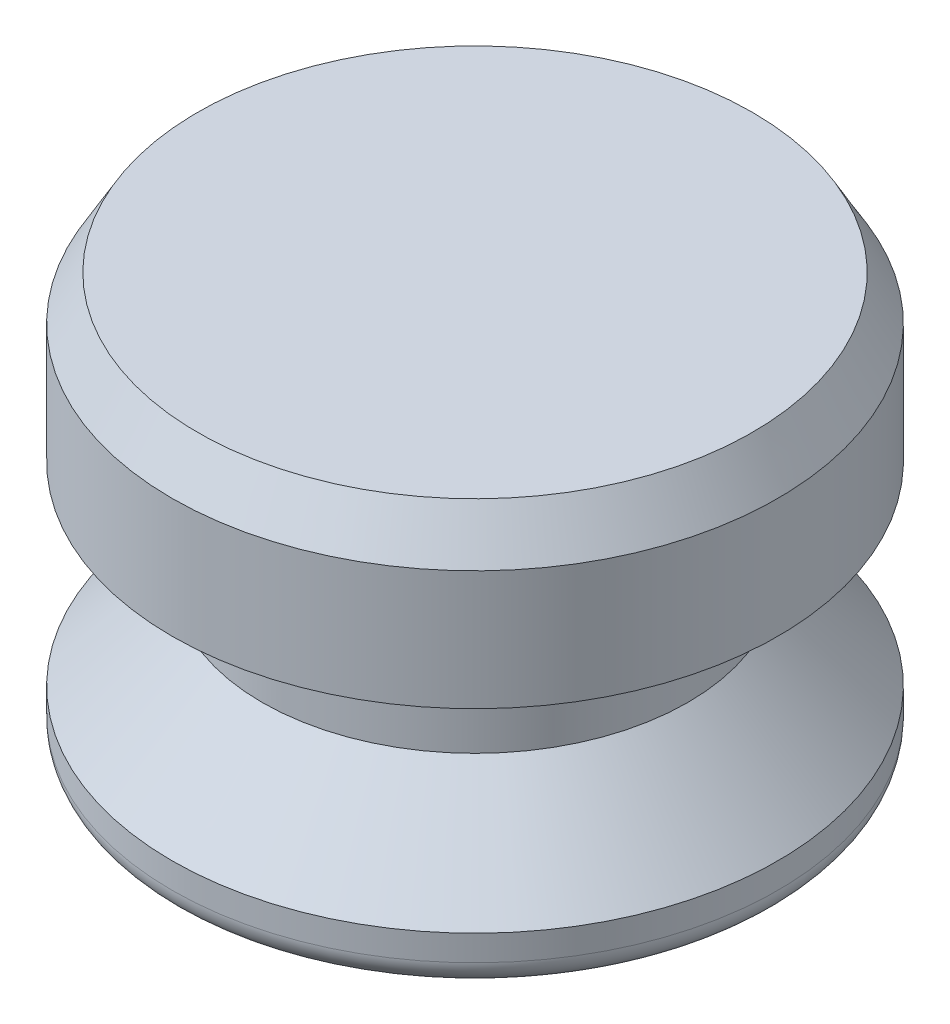
from build123d import *

# Parameters (mm, degrees)
FILLET1_R      = 0.79375
CHAMFER1_SIZE  = 0.79375
CHAMFER1_SIZE2 = 1.374815329


with BuildPart() as part:
    # Sketch1 → Revolve1 (revolve)
    with BuildSketch(Plane.XY):
        Polygon((0, 0), (-9.398, 0), (-9.398, 1.5875), (-6.604, 4.445), (-6.604, 7.62), (-9.398, 7.62), (-9.398, 12.7), (0, 12.7), align=None)
    revolve(axis=Axis((0, 0, 0), (0, 1, 0)))

    # Fillet1
    fillet1_edges = [part.edges().sort_by_distance(p)[0] for p in [
        (9.398, 0, 0),
    ]]
    fillet(fillet1_edges, radius=FILLET1_R)

    # Chamfer1
    chamfer1_edges = [part.edges().sort_by_distance(p)[0] for p in [
        (9.398, 12.7, 0),
    ]]
    chamfer1_side = [part.faces().sort_by_distance(p)[0] for p in [
        (0, 12.7, 0),
    ]]
    chamfer(chamfer1_edges, length=CHAMFER1_SIZE, length2=CHAMFER1_SIZE2, reference=chamfer1_side[0])


solid = part.part
